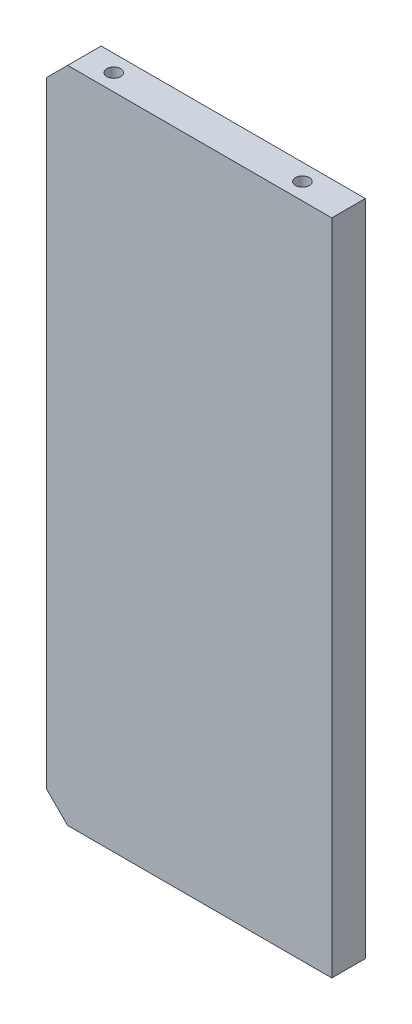
from build123d import *

# Parameters (mm, degrees)
SKETCH1_W                      = 68
SKETCH1_H                      = 157
BOSS_EXTRUDE1_DEPTH            = 8
M4X0_7_TAPPED_HOLE1_AT_2_COUNT = 2
M4X0_7_TAPPED_HOLE1_AT_2_PITCH = 45
M4X0_7_TAPPED_HOLE2_D          = 3.3
M4X0_7_TAPPED_HOLE2_DEPTH      = 10.1
M4X0_7_TAPPED_HOLE2_TIP        = 0.991420021
CHAMFER1_SIZE                  = 5


with BuildPart() as part:
    # Sketch1 → Boss-Extrude1 (new body)
    with BuildSketch(Plane.XY):
        with Locations((34, 0)):
            Rectangle(SKETCH1_W, SKETCH1_H)
    extrude(amount=-BOSS_EXTRUDE1_DEPTH)

    # Sketch4 → M4x0.7 Tapped Hole1 (revolve, cut)
    with BuildSketch(Plane(origin=(12, 78.5, -4), x_dir=(0, 0, 1), z_dir=(1, 0, 0))):
        Polygon((0, 0), (0, 17.091420021), (1.65, 16.1), (1.65, 0), align=None)
    m4x0_7_tapped_hole1 = revolve(axis=Axis((12, 84.85, -4), (0, -1, 0)), mode=Mode.SUBTRACT)

    # M4x0.7 Tapped Hole1 at 2: M4x0.7 Tapped Hole1 ×2
    with Locations(*[(i * M4X0_7_TAPPED_HOLE1_AT_2_PITCH, 0, 0) for i in range(1, M4X0_7_TAPPED_HOLE1_AT_2_COUNT)]):
        add(m4x0_7_tapped_hole1, mode=Mode.SUBTRACT)

    # M4x0.7 Tapped Hole2
    with Locations(Plane.ZY):
        with Locations((-4, 58.5), (-4, 0), (-4, -58.5)):
            Hole(M4X0_7_TAPPED_HOLE2_D / 2, depth=M4X0_7_TAPPED_HOLE2_DEPTH)
            with Locations((0, 0, -(M4X0_7_TAPPED_HOLE2_DEPTH + M4X0_7_TAPPED_HOLE2_TIP / 2))):  # 118° drill point
                Cone(0, M4X0_7_TAPPED_HOLE2_D / 2, M4X0_7_TAPPED_HOLE2_TIP, mode=Mode.SUBTRACT)

    # Mirror1: M4x0.7 Tapped Hole1 across plane
    add(m4x0_7_tapped_hole1.mirror(Plane.ZX), mode=Mode.SUBTRACT)

    # Mirror1 copy 1 sketch → Mirror1 copy 1 (revolve, cut)
    with BuildSketch(Plane(origin=(57, -78.5, -4), x_dir=(0, 0, 1), z_dir=(1, 0, 0))):
        Polygon((0, 0), (0, -17.091420021), (1.65, -16.1), (1.65, 0), align=None)
    revolve(axis=Axis((57, -84.85, -4), (0, -1, 0)), mode=Mode.SUBTRACT)

    # Chamfer1
    chamfer1_edges = [part.edges().sort_by_distance(p)[0] for p in [
        (0, -78.5, -4),
        (0, 78.5, -4),
    ]]
    chamfer(chamfer1_edges, length=CHAMFER1_SIZE)


solid = part.part
